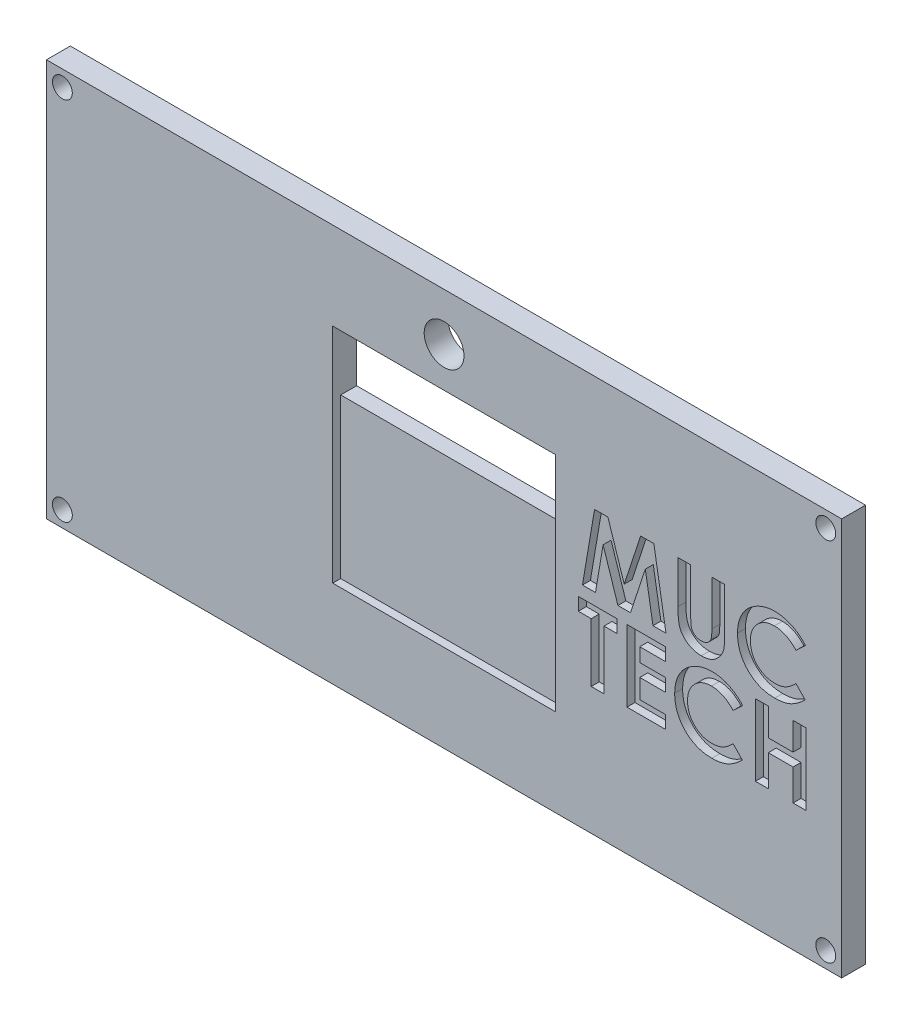
from build123d import *

# Parameters (mm, degrees)
SKIZZE1_W                        = 100
SKIZZE1_H                        = 50
AUFSATZ_LINEAR_AUSTRAGEN1_DEPTH  = 3
SKIZZE2_W                        = 28
SKIZZE2_H                        = 28
SCHNITT_LINEAR_AUSTRAGEN1_DEPTH  = 1
SKIZZE3_W                        = 28
SKIZZE3_H                        = 8
SCHNITT_LINEAR_AUSTRAGEN2_DEPTH  = 3
F_2_5_2_5_DURCHMESSER_BOHRUNG1_D = 2.5
SCHNITT_LINEAR_AUSTRAGEN3_DEPTH  = 1
F_5_0_5_DURCHMESSER_BOHRUNG1_D   = 5


with BuildPart() as part:
    # Skizze1 → Aufsatz-Linear austragen1 (new body)
    with BuildSketch(Plane.XY):
        Rectangle(SKIZZE1_W, SKIZZE1_H)
    extrude(amount=AUFSATZ_LINEAR_AUSTRAGEN1_DEPTH)

    # Skizze2 → Schnitt-Linear austragen1 (cut)
    with BuildSketch(Plane.XY.offset(3)):
        Rectangle(SKIZZE2_W, SKIZZE2_H)
    extrude(amount=-SCHNITT_LINEAR_AUSTRAGEN1_DEPTH, mode=Mode.SUBTRACT)

    # Skizze3 → Schnitt-Linear austragen2 (cut, through all)
    with BuildSketch(Plane.XY.offset(2)):
        with Locations((0, 10)):
            Rectangle(SKIZZE3_W, SKIZZE3_H)
    extrude(amount=-SCHNITT_LINEAR_AUSTRAGEN2_DEPTH, mode=Mode.SUBTRACT)

    # Ø2.5 (2.5) Durchmesser Bohrung1 (through all)
    with Locations(Plane.XY.offset(3)):
        with Locations((-48, 23), (48, 23), (48, -23), (-48, -23)):
            Hole(F_2_5_2_5_DURCHMESSER_BOHRUNG1_D / 2)

    # Skizze7 → Schnitt-Linear austragen3 (cut)
    with BuildSketch(Plane.XY.offset(3)):
        Polygon((16.884615385, 0), (21.730769231, 0), (21.730769231, -1.615384615), (20.115384615, -1.615384615), (20.115384615, -9), (18.5, -9), (18.5, -1.615384615), (16.884615385, -1.615384615), align=None)
        Polygon((23, 0), (27.846153846, 0), (27.846153846, -1.615384615), (24.615384615, -1.615384615), (24.615384615, -3.346153846), (27.846153846, -3.346153846), (27.846153846, -4.961538462), (24.615384615, -4.961538462), (24.615384615, -7.384615385), (27.846153846, -7.384615385), (27.846153846, -9), (23, -9), align=None)
        with BuildLine():
            Line((37.538461538, -1.561298077), (36.353966346, -2.693509615))
            add(Edge.make_bspline(
                [(36.353966346, -2.693509615), (36.253487814, -2.589614645), (36.057221762, -2.386675218), (35.740963292, -2.118001302), (35.412065999, -1.894097945), (35.076927922, -1.705527964), (34.729520899, -1.562861333), (34.373861901, -1.458897757), (34.007679942, -1.395515094), (33.759862077, -1.388262995), (33.635216346, -1.384615385)],
                knots=[0, 0, 0, 0, 0.000433443, 0.00084665, 0.001242205, 0.001625525, 0.001998169, 0.002366174, 0.002735479, 0.003109203, 0.003109203, 0.003109203, 0.003109203], degree=3))
            add(Edge.make_bspline(
                [(33.635216346, -1.384615385), (33.531122014, -1.387497125), (33.325703318, -1.393183921), (33.024094842, -1.434873747), (32.735590748, -1.505769111), (32.45920344, -1.603476054), (32.195746199, -1.729903654), (31.944666655, -1.884954057), (31.706583834, -2.067226938), (31.484642671, -2.275779209), (31.281618696, -2.503638238), (31.102234087, -2.746763278), (30.951970701, -3.004597343), (30.828651985, -3.27452928), (30.732591472, -3.557808467), (30.663992197, -3.85424419), (30.62431621, -4.16418948), (30.618394303, -4.374887979), (30.615384615, -4.481971154)],
                knots=[0, 0, 0, 0, 0.000312232, 0.000616156, 0.000911312, 0.00120213, 0.001494042, 0.001786248, 0.002085901, 0.002392031, 0.002698511, 0.003000331, 0.003296866, 0.003592148, 0.003889187, 0.004192693, 0.004503528, 0.004824765, 0.004824765, 0.004824765, 0.004824765], degree=3))
            add(Edge.make_bspline(
                [(30.615384615, -4.481971154), (30.616251973, -4.557129619), (30.617961553, -4.705268497), (30.636675925, -4.924407012), (30.666810476, -5.137023179), (30.710422639, -5.342794941), (30.764960076, -5.54190062), (30.828944909, -5.736057892), (30.90921294, -5.922583941), (30.998311666, -6.103645145), (31.101932457, -6.274301023), (31.213654785, -6.437035565), (31.33479941, -6.591051064), (31.466150992, -6.735717899), (31.609558141, -6.868775252), (31.761314313, -6.994224316), (31.923979424, -7.108924675), (32.094174509, -7.215754861), (32.273369837, -7.308559153), (32.456703423, -7.392621912), (32.646954975, -7.460893371), (32.841808066, -7.515926395), (33.040566359, -7.562723763), (33.245173894, -7.591538341), (33.453856982, -7.613359283), (33.594891722, -7.614706599), (33.665865385, -7.615384615)],
                knots=[0, 0, 0, 0, 0.000225425, 0.000444318, 0.000659255, 0.000869289, 0.00107485, 0.001278384, 0.001481974, 0.001683543, 0.001883281, 0.002080316, 0.002275444, 0.002470698, 0.002665851, 0.002861835, 0.003060938, 0.003262555, 0.003464164, 0.003665894, 0.003867212, 0.004069786, 0.004273161, 0.004479179, 0.004689252, 0.004902061, 0.004902061, 0.004902061, 0.004902061], degree=3))
            add(Edge.make_bspline(
                [(33.665865385, -7.615384615), (33.786248914, -7.611902485), (34.022771244, -7.605061004), (34.369901773, -7.551561592), (34.700682585, -7.463558086), (34.96497487, -7.359631059), (35.172040895, -7.257001771), (35.329677199, -7.162074733), (35.492685423, -7.055888419), (35.65835814, -6.934435243), (35.82855884, -6.79917269), (36.000283087, -6.647138259), (36.177927054, -6.483338225), (36.294299856, -6.366430923), (36.353966346, -6.306490385)],
                knots=[0, 0, 0, 0, 0.000361027, 0.000709325, 0.001050875, 0.001386003, 0.001559352, 0.001743635, 0.001937652, 0.002142841, 0.002359645, 0.002589624, 0.002830732, 0.003084427, 0.003084427, 0.003084427, 0.003084427], degree=3))
            Line((36.353966346, -6.306490385), (37.502403846, -7.512620192))
            add(Edge.make_bspline(
                [(37.502403846, -7.512620192), (37.421674871, -7.590561483), (37.264109177, -7.742686214), (37.026425702, -7.958689137), (36.78904136, -8.152791775), (36.557690864, -8.332039203), (36.328584451, -8.49120951), (36.101746417, -8.630461659), (35.879744667, -8.753317539), (35.657969265, -8.857705246), (35.43504021, -8.946341251), (35.205672409, -9.022651034), (34.969164665, -9.087206364), (34.724072495, -9.139294038), (34.472681971, -9.181061321), (34.21264041, -9.209253995), (33.945596606, -9.228206992), (33.764456656, -9.229910075), (33.673076923, -9.230769231)],
                knots=[0, 0, 0, 0, 0.000336643, 0.000657054, 0.000963147, 0.001256314, 0.001534875, 0.001799562, 0.002054528, 0.00229567, 0.002534374, 0.002773825, 0.003020498, 0.00326944, 0.003525227, 0.003784648, 0.004053882, 0.004327974, 0.004327974, 0.004327974, 0.004327974], degree=3))
            add(Edge.make_bspline(
                [(33.673076923, -9.230769231), (33.505223673, -9.226490317), (33.17678152, -9.218117671), (32.695458109, -9.156082037), (32.238213788, -9.052080389), (31.803936169, -8.904993373), (31.392763341, -8.717096603), (31.004800494, -8.486743986), (30.64067294, -8.214547533), (30.303322111, -7.90369765), (29.99817223, -7.560390049), (29.728455075, -7.19177187), (29.505345033, -6.796031488), (29.320091958, -6.379015253), (29.17522649, -5.938820157), (29.073265759, -5.474970045), (29.01038732, -4.987912792), (29.00350833, -4.65524146), (29, -4.485576923)],
                knots=[0, 0, 0, 0, 0.00050347, 0.000985151, 0.001453113, 0.001908076, 0.002358238, 0.002806881, 0.003259046, 0.003719657, 0.00418065, 0.004635034, 0.005087195, 0.005540806, 0.006002038, 0.006474878, 0.006963713, 0.007472513, 0.007472513, 0.007472513, 0.007472513], degree=3))
            add(Edge.make_bspline(
                [(29, -4.485576923), (29.00148245, -4.374923159), (29.004420304, -4.155634445), (29.03529742, -3.832604402), (29.078341915, -3.517707891), (29.146628093, -3.214214582), (29.228940345, -2.918035859), (29.331306445, -2.632390841), (29.453562901, -2.356458554), (29.591769098, -2.08977707), (29.748120386, -1.83409344), (29.922781939, -1.591604389), (30.111257287, -1.360437946), (30.318075187, -1.143660963), (30.540230302, -0.939370096), (30.778725638, -0.748672436), (31.032126765, -0.568833164), (31.301119545, -0.404489898), (31.580478165, -0.255832678), (31.866679177, -0.124710661), (32.15901942, -0.015122851), (32.456262852, 0.075776196), (32.759665323, 0.143625907), (33.067061223, 0.194985949), (33.381066122, 0.223696541), (33.591893209, 0.228396648), (33.698317308, 0.230769231)],
                knots=[0, 0, 0, 0, 0.000331853, 0.000657652, 0.000972791, 0.001284695, 0.001590043, 0.001894565, 0.002194045, 0.002494824, 0.002795063, 0.003092249, 0.003390729, 0.003689137, 0.003990268, 0.004295483, 0.004604618, 0.004921865, 0.005240445, 0.005553483, 0.00586557, 0.006176404, 0.006485182, 0.006797581, 0.007110811, 0.007430105, 0.007430105, 0.007430105, 0.007430105], degree=3))
            add(Edge.make_bspline(
                [(33.698317308, 0.230769231), (33.789107976, 0.229409207), (33.969745343, 0.226703301), (34.238744695, 0.204146625), (34.505592716, 0.168721594), (34.769334008, 0.115272767), (35.031855119, 0.051822255), (35.289706226, -0.031257439), (35.546955072, -0.123865414), (35.799567089, -0.234559339), (36.047894888, -0.355391757), (36.286120997, -0.492480523), (36.518245212, -0.637389347), (36.739123799, -0.79869457), (36.95289429, -0.97054535), (37.158438861, -1.153743469), (37.353953736, -1.351343375), (37.476648017, -1.490959374), (37.538461538, -1.561298077)],
                knots=[0, 0, 0, 0, 0.000272331, 0.000541831, 0.000809296, 0.001079428, 0.001348783, 0.00161906, 0.001891695, 0.002168671, 0.002446034, 0.002719746, 0.00299284, 0.003266558, 0.003539676, 0.003815464, 0.004092106, 0.004372986, 0.004372986, 0.004372986, 0.004372986], degree=3))
        make_face()
        Polygon((39.153846154, 0), (40.769230769, 0), (40.769230769, -3.461538462), (43.884615385, -3.461538462), (43.884615385, 0), (45.5, 0), (45.5, -9), (43.884615385, -9), (43.884615385, -5.076923077), (40.769230769, -5.076923077), (40.769230769, -9), (39.153846154, -9), align=None)
        Polygon((18.923677885, 10.5), (20.600360577, 10.5), (22.653846154, 4.222355769), (24.721754808, 10.5), (26.382211538, 10.5), (27.903846154, 1.5), (26.268629808, 1.5), (25.307692308, 7.184495192), (23.436298077, 1.5), (21.860576923, 1.5), (20, 7.184495192), (19.040865385, 1.5), (17.403846154, 1.5), align=None)
        with BuildLine():
            Line((29.403846154, 10.5), (31.019230769, 10.5))
            Line((31.019230769, 10.5), (31.019230769, 4.644230769))
            add(Edge.make_bspline(
                [(31.019230769, 4.644230769), (31.019318606, 4.583520694), (31.019488261, 4.46625981), (31.027981308, 4.298028834), (31.035753032, 4.143389342), (31.049775426, 4.002510634), (31.07049131, 3.875332444), (31.090551045, 3.761037827), (31.117699912, 3.661673098), (31.15850032, 3.548570022), (31.221360354, 3.421492538), (31.324070163, 3.289049469), (31.442588495, 3.168175946), (31.584639543, 3.067565404), (31.744292358, 2.986180545), (31.920669719, 2.92588337), (32.113522997, 2.892366148), (32.246870459, 2.88724913), (32.315504808, 2.884615385)],
                knots=[0, 0, 0, 0, 0.0001821, 0.000351725, 0.000505235, 0.000646598, 0.00077613, 0.000891753, 0.000994534, 0.001084642, 0.001252349, 0.001417133, 0.001585411, 0.001758525, 0.001936719, 0.002121442, 0.002315594, 0.00252151, 0.00252151, 0.00252151, 0.00252151], degree=3))
            add(Edge.make_bspline(
                [(32.315504808, 2.884615385), (32.388420333, 2.886743112), (32.530593262, 2.890891821), (32.735086387, 2.93161589), (32.924550428, 2.996462555), (33.094973783, 3.089015273), (33.246186855, 3.199955925), (33.374185552, 3.326463034), (33.475201653, 3.468788918), (33.54104019, 3.600095384), (33.578005286, 3.720951552), (33.605712467, 3.828931952), (33.626024895, 3.956338135), (33.644452998, 4.10118038), (33.655526869, 4.264958972), (33.667534676, 4.446356784), (33.671935648, 4.646614987), (33.672685762, 4.786058533), (33.673076923, 4.858774038)],
                knots=[0, 0, 0, 0, 0.000218514, 0.000426065, 0.000622778, 0.000817172, 0.001005398, 0.001183875, 0.001354474, 0.001527024, 0.001621671, 0.001733174, 0.001861217, 0.002008359, 0.002171109, 0.002353521, 0.002553714, 0.002771871, 0.002771871, 0.002771871, 0.002771871], degree=3))
            Line((33.673076923, 4.858774038), (33.673076923, 10.5))
            Line((33.673076923, 10.5), (35.288461538, 10.5))
            Line((35.288461538, 10.5), (35.288461538, 5.131009615))
            add(Edge.make_bspline(
                [(35.288461538, 5.131009615), (35.288237213, 5.022234127), (35.287805857, 4.813069471), (35.281181528, 4.512485141), (35.267079529, 4.237949571), (35.255235478, 3.989382543), (35.232313181, 3.767118918), (35.208433525, 3.570209566), (35.17799685, 3.399352291), (35.132708906, 3.204852046), (35.054555324, 2.980892137), (34.928561502, 2.723012011), (34.768620501, 2.470531746), (34.57957823, 2.226228801), (34.366132214, 1.999279238), (34.133015008, 1.800046898), (33.883930265, 1.631517822), (33.616275228, 1.497812749), (33.330277685, 1.393532872), (33.023107903, 1.323462047), (32.694975348, 1.276121318), (32.468327991, 1.271573659), (32.3515625, 1.269230769)],
                knots=[0, 0, 0, 0, 0.000326327, 0.000627495, 0.000901824, 0.00115104, 0.001373848, 0.001571976, 0.001745971, 0.001894214, 0.002170738, 0.002455371, 0.002753496, 0.003065791, 0.003380801, 0.003686447, 0.003983967, 0.004280677, 0.004581807, 0.004894913, 0.005224333, 0.00557439, 0.00557439, 0.00557439, 0.00557439], degree=3))
            add(Edge.make_bspline(
                [(32.3515625, 1.269230769), (32.273981185, 1.270537524), (32.120914842, 1.273115724), (31.895803932, 1.295848717), (31.678190017, 1.329348601), (31.468481993, 1.378221481), (31.265952001, 1.441356115), (31.070653849, 1.519070451), (30.883313313, 1.610931011), (30.704978724, 1.716092874), (30.535869537, 1.829807327), (30.381312469, 1.955864584), (30.23598885, 2.084942236), (30.104097016, 2.222472419), (29.984646345, 2.367011299), (29.877882843, 2.51888645), (29.783965127, 2.678084381), (29.700530748, 2.847474625), (29.629119062, 3.035666677), (29.568916329, 3.249354607), (29.516321804, 3.491887758), (29.477236656, 3.763812546), (29.441801832, 4.064232736), (29.419373542, 4.393930969), (29.407640294, 4.752916704), (29.405142824, 5.001794072), (29.403846154, 5.131009615)],
                knots=[0, 0, 0, 0, 0.000232684, 0.000459081, 0.000678122, 0.000892847, 0.0011044, 0.001313977, 0.001522808, 0.001729669, 0.001934691, 0.002133475, 0.002327518, 0.002517506, 0.002704485, 0.002889551, 0.003073834, 0.003258478, 0.003455356, 0.003676751, 0.003923931, 0.004199306, 0.004500539, 0.004831298, 0.005190294, 0.005577952, 0.005577952, 0.005577952, 0.005577952], degree=3))
            Line((29.403846154, 5.131009615), (29.403846154, 10.5))
        make_face()
        with BuildLine():
            Line((45.442307692, 8.938701923), (44.2578125, 7.806490385))
            add(Edge.make_bspline(
                [(44.2578125, 7.806490385), (44.157333968, 7.910385355), (43.961067916, 8.113324782), (43.644809446, 8.381998698), (43.315912152, 8.605902055), (42.980774075, 8.794472036), (42.633367053, 8.937138667), (42.277708055, 9.041102243), (41.911526096, 9.104484906), (41.66370823, 9.111737005), (41.5390625, 9.115384615)],
                knots=[0, 0, 0, 0, 0.000433443, 0.00084665, 0.001242205, 0.001625525, 0.001998169, 0.002366174, 0.002735479, 0.003109203, 0.003109203, 0.003109203, 0.003109203], degree=3))
            add(Edge.make_bspline(
                [(41.5390625, 9.115384615), (41.434968168, 9.112502875), (41.229549472, 9.106816079), (40.927940996, 9.065126253), (40.639436902, 8.994230889), (40.363049593, 8.896523946), (40.099592353, 8.770096346), (39.848512809, 8.615045943), (39.610429987, 8.432773062), (39.388488825, 8.224220791), (39.18546485, 7.996361762), (39.00608024, 7.753236722), (38.855816855, 7.495402657), (38.732498139, 7.22547072), (38.636437626, 6.942191533), (38.567838351, 6.64575581), (38.528162364, 6.33581052), (38.522240457, 6.125112021), (38.519230769, 6.018028846)],
                knots=[0, 0, 0, 0, 0.000312232, 0.000616156, 0.000911312, 0.00120213, 0.001494042, 0.001786248, 0.002085901, 0.002392031, 0.002698511, 0.003000331, 0.003296866, 0.003592148, 0.003889187, 0.004192693, 0.004503528, 0.004824765, 0.004824765, 0.004824765, 0.004824765], degree=3))
            add(Edge.make_bspline(
                [(38.519230769, 6.018028846), (38.520098127, 5.942870381), (38.521807706, 5.794731503), (38.540522078, 5.575592988), (38.57065663, 5.362976821), (38.614268792, 5.157205059), (38.66880623, 4.95809938), (38.732791063, 4.763942108), (38.813059094, 4.577416059), (38.90215782, 4.396354855), (39.005778611, 4.225698977), (39.117500939, 4.062964435), (39.238645564, 3.908948936), (39.369997146, 3.764282101), (39.513404295, 3.631224748), (39.665160467, 3.505775684), (39.827825578, 3.391075325), (39.998020663, 3.284245139), (40.177215991, 3.191440847), (40.360549577, 3.107378088), (40.550801129, 3.039106629), (40.74565422, 2.984073605), (40.944412513, 2.937276237), (41.149020048, 2.908461659), (41.357703136, 2.886640717), (41.498737876, 2.885293401), (41.569711538, 2.884615385)],
                knots=[0, 0, 0, 0, 0.000225425, 0.000444318, 0.000659255, 0.000869289, 0.00107485, 0.001278384, 0.001481974, 0.001683543, 0.001883281, 0.002080316, 0.002275444, 0.002470698, 0.002665851, 0.002861835, 0.003060938, 0.003262555, 0.003464164, 0.003665894, 0.003867212, 0.004069786, 0.004273161, 0.004479179, 0.004689252, 0.004902061, 0.004902061, 0.004902061, 0.004902061], degree=3))
            add(Edge.make_bspline(
                [(41.569711538, 2.884615385), (41.690095068, 2.888097515), (41.926617398, 2.894938996), (42.273747927, 2.948438408), (42.604528739, 3.036441914), (42.868821024, 3.140368941), (43.075887049, 3.242998229), (43.233523352, 3.337925267), (43.396531576, 3.444111581), (43.562204294, 3.565564757), (43.732404993, 3.70082731), (43.904129241, 3.852861741), (44.081773208, 4.016661775), (44.19814601, 4.133569077), (44.2578125, 4.193509615)],
                knots=[0, 0, 0, 0, 0.000361027, 0.000709325, 0.001050875, 0.001386003, 0.001559352, 0.001743635, 0.001937652, 0.002142841, 0.002359645, 0.002589624, 0.002830732, 0.003084427, 0.003084427, 0.003084427, 0.003084427], degree=3))
            Line((44.2578125, 4.193509615), (45.40625, 2.987379808))
            add(Edge.make_bspline(
                [(45.40625, 2.987379808), (45.325521025, 2.909438517), (45.167955331, 2.757313786), (44.930271856, 2.541310863), (44.692887514, 2.347208225), (44.461537018, 2.167960797), (44.232430605, 2.00879049), (44.00559257, 1.869538341), (43.783590821, 1.746682461), (43.561815419, 1.642294754), (43.338886363, 1.553658749), (43.109518563, 1.477348966), (42.873010819, 1.412793636), (42.627918649, 1.360705962), (42.376528125, 1.318938679), (42.116486564, 1.290746005), (41.84944276, 1.271793008), (41.66830281, 1.270089925), (41.576923077, 1.269230769)],
                knots=[0, 0, 0, 0, 0.000336643, 0.000657054, 0.000963147, 0.001256314, 0.001534875, 0.001799562, 0.002054528, 0.00229567, 0.002534374, 0.002773825, 0.003020498, 0.00326944, 0.003525227, 0.003784648, 0.004053882, 0.004327974, 0.004327974, 0.004327974, 0.004327974], degree=3))
            add(Edge.make_bspline(
                [(41.576923077, 1.269230769), (41.409069827, 1.273509683), (41.080627674, 1.281882329), (40.599304262, 1.343917963), (40.142059942, 1.447919611), (39.707782323, 1.595006627), (39.296609494, 1.782903397), (38.908646648, 2.013256014), (38.544519093, 2.285452467), (38.207168264, 2.59630235), (37.902018384, 2.939609951), (37.632301228, 3.30822813), (37.409191187, 3.703968512), (37.223938112, 4.120984747), (37.079072644, 4.561179843), (36.977111913, 5.025029955), (36.914233474, 5.512087208), (36.907354484, 5.84475854), (36.903846154, 6.014423077)],
                knots=[0, 0, 0, 0, 0.00050347, 0.000985151, 0.001453113, 0.001908076, 0.002358238, 0.002806881, 0.003259046, 0.003719657, 0.00418065, 0.004635034, 0.005087195, 0.005540806, 0.006002038, 0.006474878, 0.006963713, 0.007472513, 0.007472513, 0.007472513, 0.007472513], degree=3))
            add(Edge.make_bspline(
                [(36.903846154, 6.014423077), (36.905328604, 6.125076841), (36.908266458, 6.344365555), (36.939143574, 6.667395598), (36.982188069, 6.982292109), (37.050474247, 7.285785418), (37.132786499, 7.581964141), (37.235152599, 7.867609159), (37.357409055, 8.143541446), (37.495615252, 8.41022293), (37.65196654, 8.66590656), (37.826628093, 8.908395611), (38.015103441, 9.139562054), (38.221921341, 9.356339037), (38.444076456, 9.560629904), (38.682571792, 9.751327564), (38.935972919, 9.931166836), (39.204965698, 10.095510102), (39.484324318, 10.244167322), (39.770525331, 10.375289339), (40.062865574, 10.484877149), (40.360109006, 10.575776196), (40.663511477, 10.643625907), (40.970907377, 10.694985949), (41.284912276, 10.723696541), (41.495739362, 10.728396648), (41.602163462, 10.730769231)],
                knots=[0, 0, 0, 0, 0.000331853, 0.000657652, 0.000972791, 0.001284695, 0.001590043, 0.001894565, 0.002194045, 0.002494824, 0.002795063, 0.003092249, 0.003390729, 0.003689137, 0.003990268, 0.004295483, 0.004604618, 0.004921865, 0.005240445, 0.005553483, 0.00586557, 0.006176404, 0.006485182, 0.006797581, 0.007110811, 0.007430105, 0.007430105, 0.007430105, 0.007430105], degree=3))
            add(Edge.make_bspline(
                [(41.602163462, 10.730769231), (41.69295413, 10.729409207), (41.873591497, 10.726703301), (42.142590849, 10.704146625), (42.40943887, 10.668721594), (42.673180162, 10.615272767), (42.935701272, 10.551822255), (43.19355238, 10.468742561), (43.450801226, 10.376134586), (43.703413243, 10.265440661), (43.951741041, 10.144608243), (44.189967151, 10.007519477), (44.422091366, 9.862610653), (44.642969953, 9.70130543), (44.856740444, 9.52945465), (45.062285014, 9.346256531), (45.25779989, 9.148656625), (45.38049417, 9.009040626), (45.442307692, 8.938701923)],
                knots=[0, 0, 0, 0, 0.000272331, 0.000541831, 0.000809296, 0.001079428, 0.001348783, 0.00161906, 0.001891695, 0.002168671, 0.002446034, 0.002719746, 0.00299284, 0.003266558, 0.003539676, 0.003815464, 0.004092106, 0.004372986, 0.004372986, 0.004372986, 0.004372986], degree=3))
        make_face()
    extrude(amount=-SCHNITT_LINEAR_AUSTRAGEN3_DEPTH, mode=Mode.SUBTRACT)

    # Ø5.0 (5) Durchmesser Bohrung1 (through all)
    with Locations(Plane.XY.offset(3)):
        with Locations((0, 19)):
            Hole(F_5_0_5_DURCHMESSER_BOHRUNG1_D / 2)


solid = part.part
